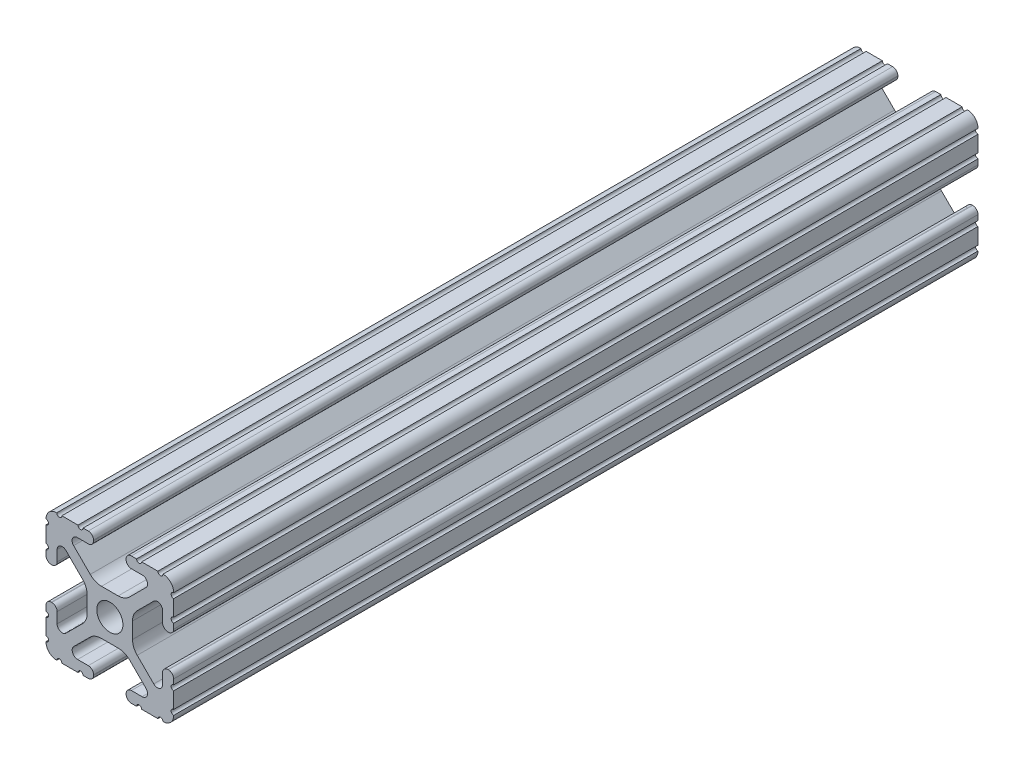
from build123d import *

# Parameters (mm, degrees)
SKETCH1_R           = 2.6035
BOSS_EXTRUDE1_DEPTH = 80


with BuildPart() as part:
    # Sketch1 → Boss-Extrude1 (new body, symmetric)
    with BuildSketch(Plane.XY):
        with BuildLine():
            Line((-7.179650497, -8.645192506), (-3.952270251, -5.423690499))
            ThreePointArc((-3.952270251, -5.423690499), (-2.922936451, -4.736929036), (-1.709253557, -4.4958))
            Line((-1.709253557, -4.4958), (1.709253557, -4.4958))
            ThreePointArc((1.709253557, -4.4958), (2.922936451, -4.736929036), (3.952270251, -5.423690499))
            Line((3.952270251, -5.423690499), (7.179650497, -8.645192506))
            ThreePointArc((7.179650497, -8.645192506), (7.41473083, -9.822813117), (6.416408329, -10.4902))
            Line((6.416408329, -10.4902), (4.287512407, -10.4902))
            ThreePointArc((4.287512407, -10.4902), (3.54574862, -10.79744862), (3.2385, -11.539212407))
            Line((3.2385, -11.539212407), (3.2385, -11.650987593))
            ThreePointArc((3.2385, -11.650987593), (3.54574862, -12.39275138), (4.287512407, -12.7))
            Line((4.287512407, -12.7), (5.317126718, -12.7))
            ThreePointArc((5.317126718, -12.7), (5.825126718, -12.192), (6.333126718, -12.7))
            Line((6.333126718, -12.7), (9.550443118, -12.7))
            ThreePointArc((9.550443118, -12.7), (10.058366869, -12.192000006), (10.566443095, -12.699847501))
            ThreePointArc((10.566443095, -12.699847501), (12.082537762, -12.08250727), (12.699846982, -10.566399977))
            ThreePointArc((12.699846982, -10.566399977), (12.192000006, -10.058323491), (12.7, -9.5504))
            Line((12.7, -9.5504), (12.7, -6.3330836))
            ThreePointArc((12.7, -6.3330836), (12.192, -5.8250836), (12.7, -5.3170836))
            Line((12.7, -5.3170836), (12.7, -4.287469289))
            ThreePointArc((12.7, -4.287469289), (12.39275138, -3.545705502), (11.650987593, -3.238456882))
            Line((11.650987593, -3.238456882), (11.539212407, -3.238456882))
            ThreePointArc((11.539212407, -3.238456882), (10.79744862, -3.545705502), (10.4902, -4.287469289))
            Line((10.4902, -4.287469289), (10.4902, -6.402089023))
            ThreePointArc((10.4902, -6.402089023), (9.856505071, -7.351067942), (8.737131347, -7.129408934))
            Line((8.737131347, -7.129408934), (5.441005833, -3.840816462))
            ThreePointArc((5.441005833, -3.840816462), (4.750877967, -2.809883091), (4.5085, -1.593185507))
            Line((4.5085, -1.593185507), (4.5085, 1.593185507))
            ThreePointArc((4.5085, 1.593185507), (4.750877967, 2.809883091), (5.441005833, 3.840816462))
            Line((5.441005833, 3.840816462), (8.737131347, 7.129408934))
            ThreePointArc((8.737131347, 7.129408934), (9.856505071, 7.351067942), (10.4902, 6.402089023))
            Line((10.4902, 6.402089023), (10.4902, 4.287469289))
            ThreePointArc((10.4902, 4.287469289), (10.79744862, 3.545705502), (11.539212407, 3.238456882))
            Line((11.539212407, 3.238456882), (11.650987593, 3.238456882))
            ThreePointArc((11.650987593, 3.238456882), (12.39275138, 3.545705502), (12.7, 4.287469289))
            Line((12.7, 4.287469289), (12.7, 5.3170836))
            ThreePointArc((12.7, 5.3170836), (12.192, 5.8250836), (12.7, 6.3330836))
            Line((12.7, 6.3330836), (12.7, 9.5504))
            ThreePointArc((12.7, 9.5504), (12.192000006, 10.058323491), (12.699846982, 10.566399977))
            ThreePointArc((12.699846982, 10.566399977), (12.082537762, 12.08250727), (10.566443095, 12.699847501))
            ThreePointArc((10.566443095, 12.699847501), (10.058366869, 12.192000006), (9.550443118, 12.7))
            Line((9.550443118, 12.7), (6.333126718, 12.7))
            ThreePointArc((6.333126718, 12.7), (5.825126718, 12.192), (5.317126718, 12.7))
            Line((5.317126718, 12.7), (4.287512407, 12.7))
            ThreePointArc((4.287512407, 12.7), (3.54574862, 12.39275138), (3.2385, 11.650987593))
            Line((3.2385, 11.650987593), (3.2385, 11.539212407))
            ThreePointArc((3.2385, 11.539212407), (3.54574862, 10.79744862), (4.287512407, 10.4902))
            Line((4.287512407, 10.4902), (6.476788598, 10.4902))
            ThreePointArc((6.476788598, 10.4902), (7.432222385, 9.85140422), (7.207036008, 8.724370562))
            Line((7.207036008, 8.724370562), (3.898272566, 5.423169045))
            ThreePointArc((3.898272566, 5.423169045), (2.869120213, 4.736787962), (1.655778399, 4.4958))
            Line((1.655778399, 4.4958), (-1.655778399, 4.4958))
            ThreePointArc((-1.655778399, 4.4958), (-2.869120213, 4.736787962), (-3.898272566, 5.423169045))
            Line((-3.898272566, 5.423169045), (-7.207036008, 8.724370562))
            ThreePointArc((-7.207036008, 8.724370562), (-7.432222385, 9.85140422), (-6.476788598, 10.4902))
            Line((-6.476788598, 10.4902), (-4.287512407, 10.4902))
            ThreePointArc((-4.287512407, 10.4902), (-3.54574862, 10.79744862), (-3.2385, 11.539212407))
            Line((-3.2385, 11.539212407), (-3.2385, 11.650987593))
            ThreePointArc((-3.2385, 11.650987593), (-3.54574862, 12.39275138), (-4.287512407, 12.7))
            Line((-4.287512407, 12.7), (-5.317126718, 12.7))
            ThreePointArc((-5.317126718, 12.7), (-5.825126718, 12.192), (-6.333126718, 12.7))
            Line((-6.333126718, 12.7), (-9.550443118, 12.7))
            ThreePointArc((-9.550443118, 12.7), (-10.058366869, 12.192000006), (-10.566443095, 12.699847501))
            ThreePointArc((-10.566443095, 12.699847501), (-12.082537762, 12.08250727), (-12.699846982, 10.566399977))
            ThreePointArc((-12.699846982, 10.566399977), (-12.192000006, 10.058323491), (-12.7, 9.5504))
            Line((-12.7, 9.5504), (-12.7, 6.3330836))
            ThreePointArc((-12.7, 6.3330836), (-12.192, 5.8250836), (-12.7, 5.3170836))
            Line((-12.7, 5.3170836), (-12.7, 4.287469289))
            ThreePointArc((-12.7, 4.287469289), (-12.39275138, 3.545705502), (-11.650987593, 3.238456882))
            Line((-11.650987593, 3.238456882), (-11.539212407, 3.238456882))
            ThreePointArc((-11.539212407, 3.238456882), (-10.79744862, 3.545705502), (-10.4902, 4.287469289))
            Line((-10.4902, 4.287469289), (-10.4902, 6.402089023))
            ThreePointArc((-10.4902, 6.402089023), (-9.856505071, 7.351067942), (-8.737131347, 7.129408934))
            Line((-8.737131347, 7.129408934), (-5.441005833, 3.840816462))
            ThreePointArc((-5.441005833, 3.840816462), (-4.750877967, 2.809883091), (-4.5085, 1.593185507))
            Line((-4.5085, 1.593185507), (-4.5085, -1.593185507))
            ThreePointArc((-4.5085, -1.593185507), (-4.750877967, -2.809883091), (-5.441005833, -3.840816462))
            Line((-5.441005833, -3.840816462), (-8.737131347, -7.129408934))
            ThreePointArc((-8.737131347, -7.129408934), (-9.856505071, -7.351067942), (-10.4902, -6.402089023))
            Line((-10.4902, -6.402089023), (-10.4902, -4.287469289))
            ThreePointArc((-10.4902, -4.287469289), (-10.79744862, -3.545705502), (-11.539212407, -3.238456882))
            Line((-11.539212407, -3.238456882), (-11.650987593, -3.238456882))
            ThreePointArc((-11.650987593, -3.238456882), (-12.39275138, -3.545705502), (-12.7, -4.287469289))
            Line((-12.7, -4.287469289), (-12.7, -5.3170836))
            ThreePointArc((-12.7, -5.3170836), (-12.192, -5.8250836), (-12.7, -6.3330836))
            Line((-12.7, -6.3330836), (-12.7, -9.5504))
            ThreePointArc((-12.7, -9.5504), (-12.192000006, -10.058323491), (-12.699846982, -10.566399977))
            ThreePointArc((-12.699846982, -10.566399977), (-12.082537762, -12.08250727), (-10.566443095, -12.699847501))
            ThreePointArc((-10.566443095, -12.699847501), (-10.058366869, -12.192000006), (-9.550443118, -12.7))
            Line((-9.550443118, -12.7), (-6.333126718, -12.7))
            ThreePointArc((-6.333126718, -12.7), (-5.825126718, -12.192), (-5.317126718, -12.7))
            Line((-5.317126718, -12.7), (-4.287512407, -12.7))
            ThreePointArc((-4.287512407, -12.7), (-3.54574862, -12.39275138), (-3.2385, -11.650987593))
            Line((-3.2385, -11.650987593), (-3.2385, -11.539212407))
            ThreePointArc((-3.2385, -11.539212407), (-3.54574862, -10.79744862), (-4.287512407, -10.4902))
            Line((-4.287512407, -10.4902), (-6.416408329, -10.4902))
            ThreePointArc((-6.416408329, -10.4902), (-7.41473083, -9.822813117), (-7.179650497, -8.645192506))
        make_face()
        Circle(SKETCH1_R, mode=Mode.SUBTRACT)
    extrude(amount=BOSS_EXTRUDE1_DEPTH, both=True)


solid = part.part
